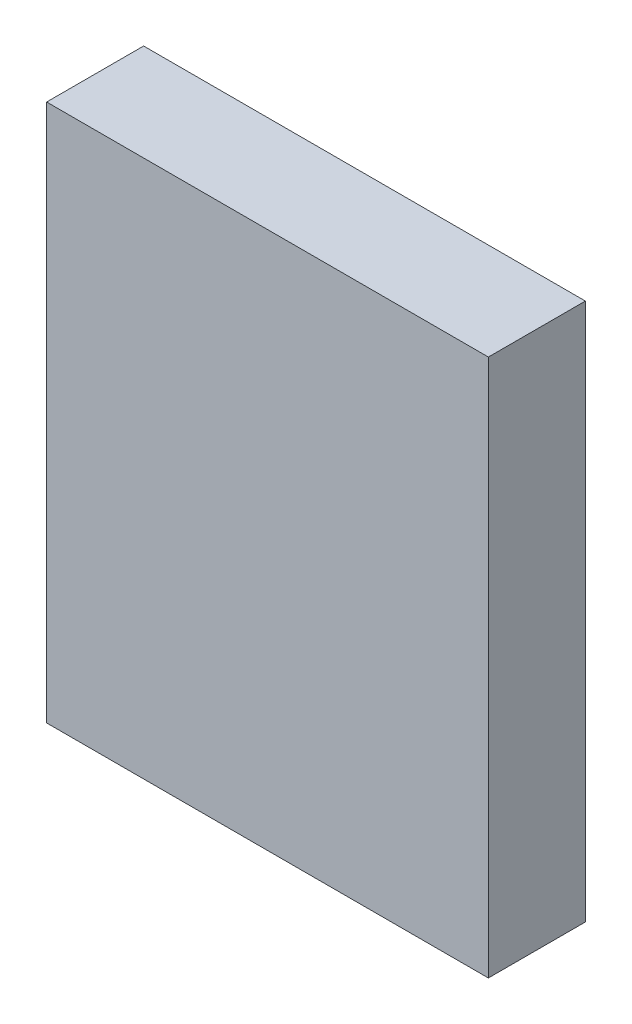
from build123d import *

# Parameters (mm, degrees)
SCHIZZO1_W                   = 46
SCHIZZO1_H                   = 56
ESTRUSIONE_ESTRUSIONE1_DEPTH = 10.1


with BuildPart() as part:
    # Schizzo1 → Estrusione-Estrusione1 (new body)
    with BuildSketch(Plane.XY):
        with Locations((23, 28)):
            Rectangle(SCHIZZO1_W, SCHIZZO1_H)
    extrude(amount=ESTRUSIONE_ESTRUSIONE1_DEPTH)


solid = part.part
